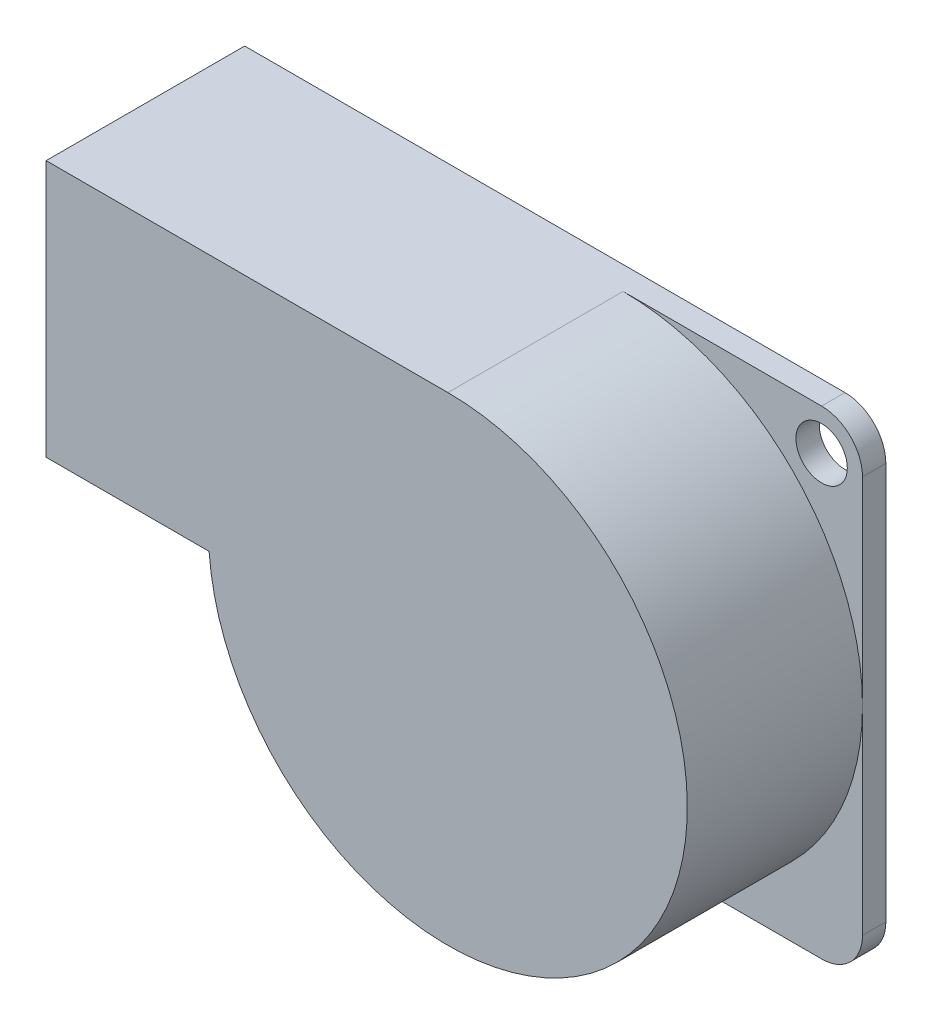
from build123d import *

# Parameters (mm, degrees)
SKETCH1_R           = 1.1
BOSS_EXTRUDE1_DEPTH = 1
BOSS_EXTRUDE2_DEPTH = 7.5


with BuildPart() as part:
    # Sketch1 → Boss-Extrude1 (new body)
    with BuildSketch(Plane.XY):
        with BuildLine():
            Line((0, 1.75), (-25.7, 1.75))
            Line((-25.7, 1.75), (-25.7, -9.25))
            Line((-25.7, -9.25), (-18.75, -9.25))
            Line((-18.75, -9.25), (-18.75, -17))
            ThreePointArc((-18.75, -17), (-18.237436867, -18.237436867), (-17, -18.75))
            Line((-17, -18.75), (0, -18.75))
            ThreePointArc((0, -18.75), (1.237436867, -18.237436867), (1.75, -17))
            Line((1.75, -17), (1.75, 0))
            ThreePointArc((1.75, 0), (1.237436867, 1.237436867), (0, 1.75))
        make_face()
        Circle(SKETCH1_R, mode=Mode.SUBTRACT)
        with Locations((-17, -17)):
            Circle(SKETCH1_R, mode=Mode.SUBTRACT)
    extrude(amount=BOSS_EXTRUDE1_DEPTH)

    # Sketch2 → Boss-Extrude2 (add)
    with BuildSketch(Plane.XY.offset(1)):
        with BuildLine():
            Line((-25.7, -9.25), (-18.72252415, -9.25))
            ThreePointArc((-18.72252415, -9.25), (-0.991671291, -15.477642868), (-8.5, 1.75))
            Line((-8.5, 1.75), (-25.7, 1.75))
            Line((-25.7, 1.75), (-25.7, -9.25))
        make_face()
    extrude(amount=BOSS_EXTRUDE2_DEPTH)


solid = part.part
